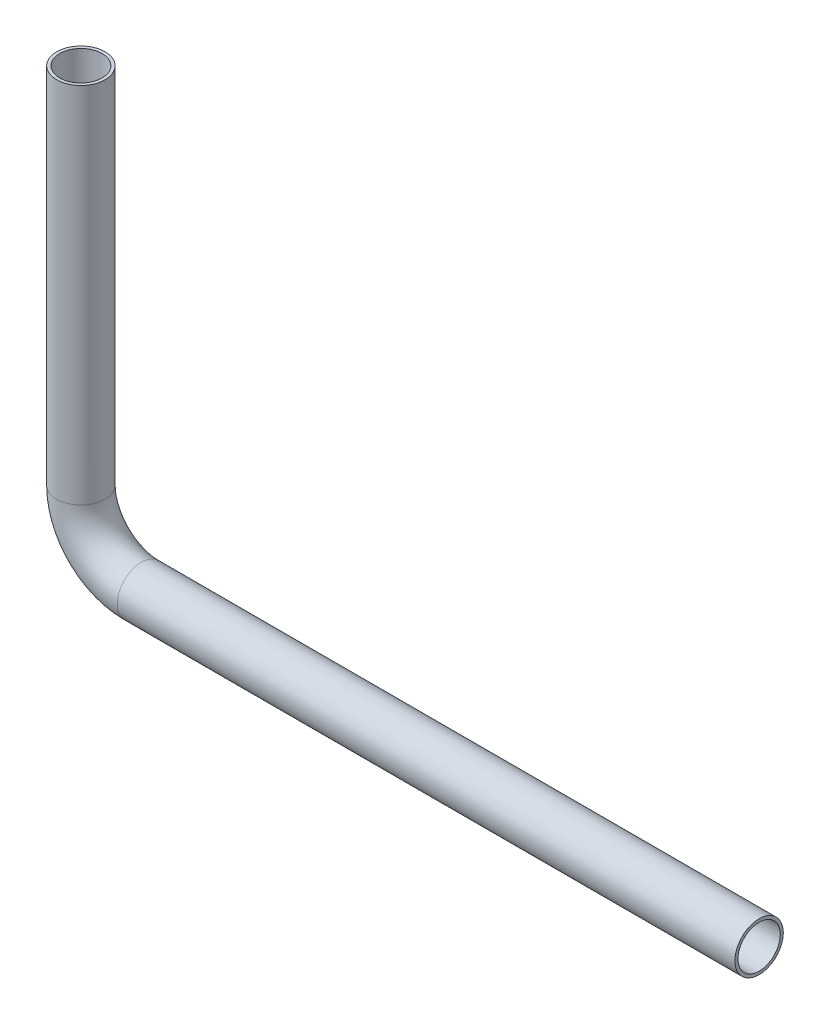
from build123d import *

# Parameters (mm, degrees)
SWEEP1_PROFILE_R = 4
SHELL1_T         = -0.5


with BuildPart() as part:
    # Sweep1: sweep along a path in Sketch1
    with BuildLine(Plane.XY) as sweep1_path:
        Line((0, 0), (-102, 0))
        ThreePointArc((-102, 0), (-109.071067812, 2.928932188), (-112, 10))
        Line((-112, 10), (-112, 70))
    # Sweep1 profile (on start of the path) → Sweep1 (sweep)
    with BuildSketch(Plane(origin=(0, 0, 0), x_dir=(0, 0, -1), z_dir=(-1, 0, 0))):
        Circle(SWEEP1_PROFILE_R)
    sweep(path=sweep1_path.line)

    # Shell1
    shell1_openings = [part.faces().sort_by_distance(p)[0] for p in [
        (-112, 70, 0),
        (0, 0, 0),
    ]]
    offset(amount=SHELL1_T, openings=shell1_openings, kind=Kind.INTERSECTION)


solid = part.part
